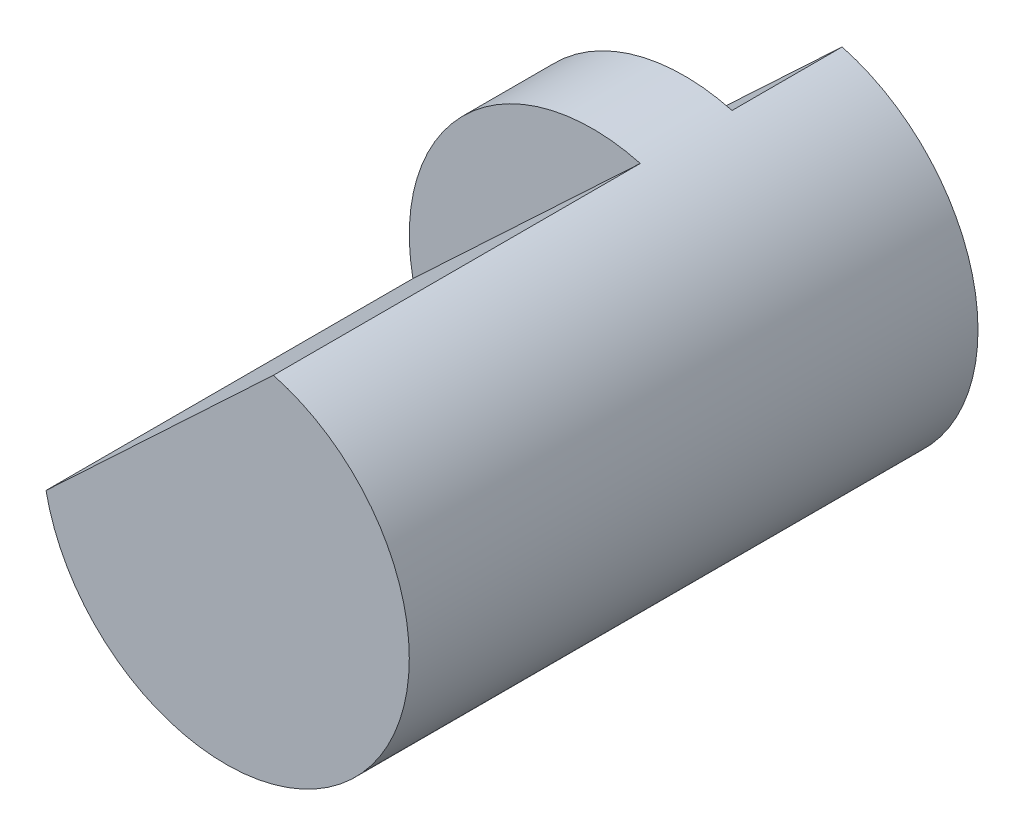
from build123d import *
from build123d.topology import SkipClean

# Parameters (mm, degrees)
BOSS_EXTRUDE1_DEPTH = 19
BOSS_EXTRUDE2_DEPTH = 13
BOSS_EXTRUDE4_DEPTH = 12
CUT_EXTRUDE1_START  = -8
CUT_EXTRUDE1_DEPTH  = 8


with BuildPart() as part:
    # Sketch1 → Boss-Extrude1 (new body)
    with BuildSketch(Plane.XY):
        with BuildLine():
            Line((-9.802855139, -1.975862122), (2.592825606, 9.658015085))
            ThreePointArc((2.592825606, 9.658015085), (6.84345718, -7.291576909), (-9.802855139, -1.975862122))
        make_face()
    extrude(amount=BOSS_EXTRUDE1_DEPTH)

    # Sketch2 → Boss-Extrude2 (add, through all)
    with BuildSketch(Plane(origin=(0, 0, 6), x_dir=(-1, 0, 0), z_dir=(0, 0, -1))):
        with BuildLine():
            Line((-2.592825606, 9.658015085), (9.802855139, -1.975862122))
            ThreePointArc((9.802855139, -1.975862122), (6.84345718, 7.291576909), (-2.592825606, 9.658015085))
        make_face()
    extrude(amount=-BOSS_EXTRUDE2_DEPTH)

    # Sketch4 → Boss-Extrude4 (add)
    with SkipClean():  # the faces are left unmerged after this step: merging them gives an invalid solid
        with BuildSketch(Plane.XY.offset(19)):
            with BuildLine():
                Line((2.592825606, 9.658015085), (-9.802855139, -1.975862122))
                ThreePointArc((-9.802855139, -1.975862122), (6.84345718, -7.291576909), (2.592825606, 9.658015085))
            make_face()
        extrude(amount=BOSS_EXTRUDE4_DEPTH)

    # Sketch5 → Cut-Extrude1 (cut)
    with SkipClean():  # the faces are left unmerged after this step: merging them gives an invalid solid
        with BuildSketch(Plane.XY.offset(19).offset(CUT_EXTRUDE1_START)):
            with BuildLine():
                Line((2.592825606, 9.658015085), (-9.802855139, -1.975862122))
                ThreePointArc((-9.802855139, -1.975862122), (-6.84345718, 7.291576909), (2.592825606, 9.658015085))
            make_face()
        extrude(amount=CUT_EXTRUDE1_DEPTH, mode=Mode.SUBTRACT)


solid = part.part
